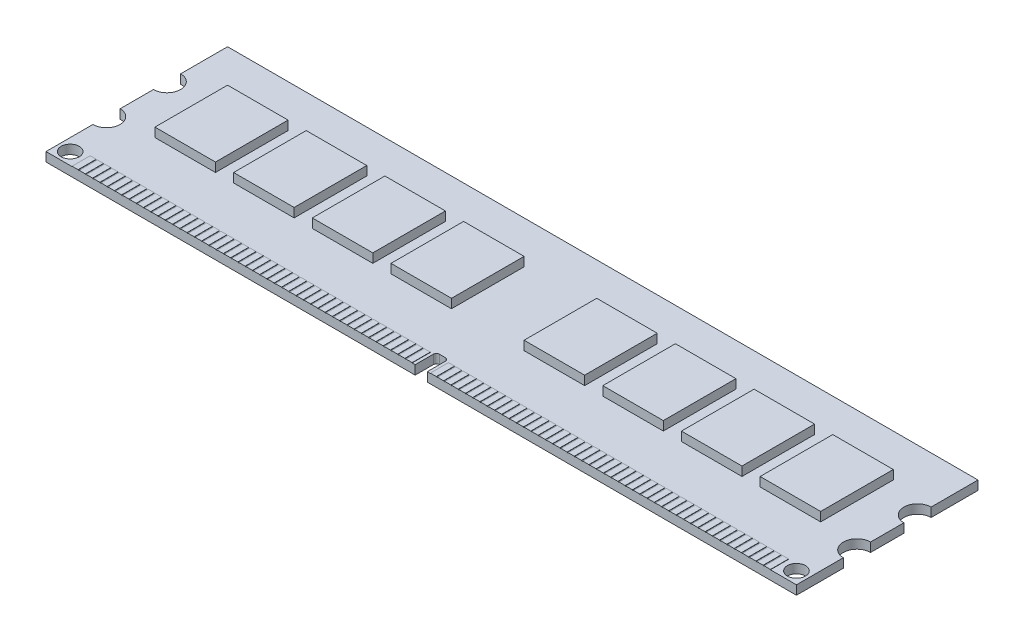
from build123d import *

# Parameters (mm, degrees)
SKETCH1_R                = 1.5
BOSS_EXTRUDE1_DEPTH      = 1.5
SKETCH2_W                = 1
SKETCH2_H                = 3
BOSS_EXTRUDE2_DEPTH      = 0.05
LPATTERN1_COUNT          = 47
LPATTERN1_PITCH          = 1.2
SKETCH3_W                = 10
SKETCH3_H                = 12
BOSS_EXTRUDE3_DEPTH      = 1.5
LPATTERN2_COUNT          = 4
LPATTERN2_PITCH          = 13
MIRROR1_COPY_1_SKETCH_W  = 1
MIRROR1_COPY_1_SKETCH_H  = 3
MIRROR1_COPY_1_DEPTH     = 0.05
MIRROR1_COPY_2_SKETCH_W  = 1
MIRROR1_COPY_2_SKETCH_H  = 3
MIRROR1_COPY_2_DEPTH     = 0.05
MIRROR1_COPY_3_SKETCH_W  = 1
MIRROR1_COPY_3_SKETCH_H  = 3
MIRROR1_COPY_3_DEPTH     = 0.05
MIRROR1_COPY_4_SKETCH_W  = 1
MIRROR1_COPY_4_SKETCH_H  = 3
MIRROR1_COPY_4_DEPTH     = 0.05
MIRROR1_COPY_5_SKETCH_W  = 1
MIRROR1_COPY_5_SKETCH_H  = 3
MIRROR1_COPY_5_DEPTH     = 0.05
MIRROR1_COPY_6_SKETCH_W  = 1
MIRROR1_COPY_6_SKETCH_H  = 3
MIRROR1_COPY_6_DEPTH     = 0.05
MIRROR1_COPY_7_SKETCH_W  = 1
MIRROR1_COPY_7_SKETCH_H  = 3
MIRROR1_COPY_7_DEPTH     = 0.05
MIRROR1_COPY_8_SKETCH_W  = 1
MIRROR1_COPY_8_SKETCH_H  = 3
MIRROR1_COPY_8_DEPTH     = 0.05
MIRROR1_COPY_9_SKETCH_W  = 1
MIRROR1_COPY_9_SKETCH_H  = 3
MIRROR1_COPY_9_DEPTH     = 0.05
MIRROR1_COPY_10_SKETCH_W = 1
MIRROR1_COPY_10_SKETCH_H = 3
MIRROR1_COPY_10_DEPTH    = 0.05
MIRROR1_COPY_11_SKETCH_W = 1
MIRROR1_COPY_11_SKETCH_H = 3
MIRROR1_COPY_11_DEPTH    = 0.05
MIRROR1_COPY_12_SKETCH_W = 1
MIRROR1_COPY_12_SKETCH_H = 3
MIRROR1_COPY_12_DEPTH    = 0.05
MIRROR1_COPY_13_SKETCH_W = 1
MIRROR1_COPY_13_SKETCH_H = 3
MIRROR1_COPY_13_DEPTH    = 0.05
MIRROR1_COPY_14_SKETCH_W = 1
MIRROR1_COPY_14_SKETCH_H = 3
MIRROR1_COPY_14_DEPTH    = 0.05
MIRROR1_COPY_15_SKETCH_W = 1
MIRROR1_COPY_15_SKETCH_H = 3
MIRROR1_COPY_15_DEPTH    = 0.05
MIRROR1_COPY_16_SKETCH_W = 1
MIRROR1_COPY_16_SKETCH_H = 3
MIRROR1_COPY_16_DEPTH    = 0.05
MIRROR1_COPY_17_SKETCH_W = 1
MIRROR1_COPY_17_SKETCH_H = 3
MIRROR1_COPY_17_DEPTH    = 0.05
MIRROR1_COPY_18_SKETCH_W = 1
MIRROR1_COPY_18_SKETCH_H = 3
MIRROR1_COPY_18_DEPTH    = 0.05
MIRROR1_COPY_19_SKETCH_W = 1
MIRROR1_COPY_19_SKETCH_H = 3
MIRROR1_COPY_19_DEPTH    = 0.05
MIRROR1_COPY_20_SKETCH_W = 1
MIRROR1_COPY_20_SKETCH_H = 3
MIRROR1_COPY_20_DEPTH    = 0.05
MIRROR1_COPY_21_SKETCH_W = 1
MIRROR1_COPY_21_SKETCH_H = 3
MIRROR1_COPY_21_DEPTH    = 0.05
MIRROR1_COPY_22_SKETCH_W = 1
MIRROR1_COPY_22_SKETCH_H = 3
MIRROR1_COPY_22_DEPTH    = 0.05
MIRROR1_COPY_23_SKETCH_W = 1
MIRROR1_COPY_23_SKETCH_H = 3
MIRROR1_COPY_23_DEPTH    = 0.05
MIRROR1_COPY_24_SKETCH_W = 1
MIRROR1_COPY_24_SKETCH_H = 3
MIRROR1_COPY_24_DEPTH    = 0.05
MIRROR1_COPY_25_SKETCH_W = 1
MIRROR1_COPY_25_SKETCH_H = 3
MIRROR1_COPY_25_DEPTH    = 0.05
MIRROR1_COPY_26_SKETCH_W = 1
MIRROR1_COPY_26_SKETCH_H = 3
MIRROR1_COPY_26_DEPTH    = 0.05
MIRROR1_COPY_27_SKETCH_W = 1
MIRROR1_COPY_27_SKETCH_H = 3
MIRROR1_COPY_27_DEPTH    = 0.05
MIRROR1_COPY_28_SKETCH_W = 1
MIRROR1_COPY_28_SKETCH_H = 3
MIRROR1_COPY_28_DEPTH    = 0.05
MIRROR1_COPY_29_SKETCH_W = 1
MIRROR1_COPY_29_SKETCH_H = 3
MIRROR1_COPY_29_DEPTH    = 0.05
MIRROR1_COPY_30_SKETCH_W = 1
MIRROR1_COPY_30_SKETCH_H = 3
MIRROR1_COPY_30_DEPTH    = 0.05
MIRROR1_COPY_31_SKETCH_W = 1
MIRROR1_COPY_31_SKETCH_H = 3
MIRROR1_COPY_31_DEPTH    = 0.05
MIRROR1_COPY_32_SKETCH_W = 1
MIRROR1_COPY_32_SKETCH_H = 3
MIRROR1_COPY_32_DEPTH    = 0.05
MIRROR1_COPY_33_SKETCH_W = 1
MIRROR1_COPY_33_SKETCH_H = 3
MIRROR1_COPY_33_DEPTH    = 0.05
MIRROR1_COPY_34_SKETCH_W = 1
MIRROR1_COPY_34_SKETCH_H = 3
MIRROR1_COPY_34_DEPTH    = 0.05
MIRROR1_COPY_35_SKETCH_W = 1
MIRROR1_COPY_35_SKETCH_H = 3
MIRROR1_COPY_35_DEPTH    = 0.05
MIRROR1_COPY_36_SKETCH_W = 1
MIRROR1_COPY_36_SKETCH_H = 3
MIRROR1_COPY_36_DEPTH    = 0.05
MIRROR1_COPY_37_SKETCH_W = 1
MIRROR1_COPY_37_SKETCH_H = 3
MIRROR1_COPY_37_DEPTH    = 0.05
MIRROR1_COPY_38_SKETCH_W = 1
MIRROR1_COPY_38_SKETCH_H = 3
MIRROR1_COPY_38_DEPTH    = 0.05
MIRROR1_COPY_39_SKETCH_W = 1
MIRROR1_COPY_39_SKETCH_H = 3
MIRROR1_COPY_39_DEPTH    = 0.05
MIRROR1_COPY_40_SKETCH_W = 1
MIRROR1_COPY_40_SKETCH_H = 3
MIRROR1_COPY_40_DEPTH    = 0.05
MIRROR1_COPY_41_SKETCH_W = 1
MIRROR1_COPY_41_SKETCH_H = 3
MIRROR1_COPY_41_DEPTH    = 0.05
MIRROR1_COPY_42_SKETCH_W = 1
MIRROR1_COPY_42_SKETCH_H = 3
MIRROR1_COPY_42_DEPTH    = 0.05
MIRROR1_COPY_43_SKETCH_W = 1
MIRROR1_COPY_43_SKETCH_H = 3
MIRROR1_COPY_43_DEPTH    = 0.05
MIRROR1_COPY_44_SKETCH_W = 1
MIRROR1_COPY_44_SKETCH_H = 3
MIRROR1_COPY_44_DEPTH    = 0.05
MIRROR1_COPY_45_SKETCH_W = 1
MIRROR1_COPY_45_SKETCH_H = 3
MIRROR1_COPY_45_DEPTH    = 0.05
MIRROR1_COPY_46_SKETCH_W = 1
MIRROR1_COPY_46_SKETCH_H = 3
MIRROR1_COPY_46_DEPTH    = 0.05
MIRROR1_COPY_47_SKETCH_W = 10
MIRROR1_COPY_47_SKETCH_H = 12
MIRROR1_COPY_47_DEPTH    = 1.5
MIRROR1_COPY_48_SKETCH_W = 10
MIRROR1_COPY_48_SKETCH_H = 12
MIRROR1_COPY_48_DEPTH    = 1.5
MIRROR1_COPY_49_SKETCH_W = 10
MIRROR1_COPY_49_SKETCH_H = 12
MIRROR1_COPY_49_DEPTH    = 1.5


with BuildPart() as part:
    # Sketch1 → Boss-Extrude1 (new body)
    with BuildSketch(Plane(origin=(0, 0, 0), x_dir=(1, 0, 0), z_dir=(0, 1, 0))):
        with BuildLine():
            Line((1, 0), (1, 3))
            ThreePointArc((1, 3), (0.853553391, 3.353553391), (0.5, 3.5))
            Line((0.5, 3.5), (0, 3.5))
            Line((0, 3.5), (0, 30))
            Line((0, 30), (62, 30))
            Line((62, 30), (62, 22.25))
            ThreePointArc((62, 22.25), (59.75, 20), (62, 17.75))
            Line((62, 17.75), (62, 12.25))
            ThreePointArc((62, 12.25), (59.75, 10), (62, 7.75))
            Line((62, 7.75), (62, 0))
            Line((62, 0), (1, 0))
        make_face()
        with Locations((60, 2)):
            Circle(SKETCH1_R, mode=Mode.SUBTRACT)
    boss_extrude1 = extrude(amount=BOSS_EXTRUDE1_DEPTH)

    # Sketch2 → Boss-Extrude2 (add)
    with BuildSketch(Plane(origin=(0, 1.5, 0), x_dir=(1, 0, 0), z_dir=(0, 1, 0))):
        with Locations((2, 1.5)):
            Rectangle(SKETCH2_W, SKETCH2_H)
    boss_extrude2 = extrude(amount=BOSS_EXTRUDE2_DEPTH)

    # LPattern1: Boss-Extrude2 ×47
    with Locations(*[(i * LPATTERN1_PITCH, 0, 0) for i in range(1, LPATTERN1_COUNT)]):
        add(boss_extrude2)

    # Sketch3 → Boss-Extrude3 (add)
    with BuildSketch(Plane(origin=(0, 1.5, 0), x_dir=(1, 0, 0), z_dir=(0, 1, 0))):
        with Locations((50, 17)):
            Rectangle(SKETCH3_W, SKETCH3_H)
    boss_extrude3 = extrude(amount=BOSS_EXTRUDE3_DEPTH)

    # LPattern2: Boss-Extrude3 ×4
    with Locations(*[(-i * LPATTERN2_PITCH, 0, 0) for i in range(1, LPATTERN2_COUNT)]):
        add(boss_extrude3)

    # Mirror1: Boss-Extrude3, Boss-Extrude2, Boss-Extrude1 across plane
    add(boss_extrude3.mirror(Plane(origin=(0, 0, 0), x_dir=(0, 0, 1), z_dir=(1, 0, 0))))
    add(boss_extrude2.mirror(Plane(origin=(0, 0, 0), x_dir=(0, 0, 1), z_dir=(1, 0, 0))))
    add(boss_extrude1.mirror(Plane(origin=(0, 0, 0), x_dir=(0, 0, 1), z_dir=(1, 0, 0))))

    # Mirror1 copy 1 sketch → Mirror1 copy 1 (add)
    with BuildSketch(Plane(origin=(-1.2, 1.5, 0), x_dir=(-1, 0, 0), z_dir=(0, 1, 0))):
        with Locations((2, -1.5)):
            Rectangle(MIRROR1_COPY_1_SKETCH_W, MIRROR1_COPY_1_SKETCH_H)
    extrude(amount=MIRROR1_COPY_1_DEPTH)

    # Mirror1 copy 2 sketch → Mirror1 copy 2 (add)
    with BuildSketch(Plane(origin=(-2.4, 1.5, 0), x_dir=(-1, 0, 0), z_dir=(0, 1, 0))):
        with Locations((2, -1.5)):
            Rectangle(MIRROR1_COPY_2_SKETCH_W, MIRROR1_COPY_2_SKETCH_H)
    extrude(amount=MIRROR1_COPY_2_DEPTH)

    # Mirror1 copy 3 sketch → Mirror1 copy 3 (add)
    with BuildSketch(Plane(origin=(-3.6, 1.5, 0), x_dir=(-1, 0, 0), z_dir=(0, 1, 0))):
        with Locations((2, -1.5)):
            Rectangle(MIRROR1_COPY_3_SKETCH_W, MIRROR1_COPY_3_SKETCH_H)
    extrude(amount=MIRROR1_COPY_3_DEPTH)

    # Mirror1 copy 4 sketch → Mirror1 copy 4 (add)
    with BuildSketch(Plane(origin=(-4.8, 1.5, 0), x_dir=(-1, 0, 0), z_dir=(0, 1, 0))):
        with Locations((2, -1.5)):
            Rectangle(MIRROR1_COPY_4_SKETCH_W, MIRROR1_COPY_4_SKETCH_H)
    extrude(amount=MIRROR1_COPY_4_DEPTH)

    # Mirror1 copy 5 sketch → Mirror1 copy 5 (add)
    with BuildSketch(Plane(origin=(-6, 1.5, 0), x_dir=(-1, 0, 0), z_dir=(0, 1, 0))):
        with Locations((2, -1.5)):
            Rectangle(MIRROR1_COPY_5_SKETCH_W, MIRROR1_COPY_5_SKETCH_H)
    extrude(amount=MIRROR1_COPY_5_DEPTH)

    # Mirror1 copy 6 sketch → Mirror1 copy 6 (add)
    with BuildSketch(Plane(origin=(-7.2, 1.5, 0), x_dir=(-1, 0, 0), z_dir=(0, 1, 0))):
        with Locations((2, -1.5)):
            Rectangle(MIRROR1_COPY_6_SKETCH_W, MIRROR1_COPY_6_SKETCH_H)
    extrude(amount=MIRROR1_COPY_6_DEPTH)

    # Mirror1 copy 7 sketch → Mirror1 copy 7 (add)
    with BuildSketch(Plane(origin=(-8.4, 1.5, 0), x_dir=(-1, 0, 0), z_dir=(0, 1, 0))):
        with Locations((2, -1.5)):
            Rectangle(MIRROR1_COPY_7_SKETCH_W, MIRROR1_COPY_7_SKETCH_H)
    extrude(amount=MIRROR1_COPY_7_DEPTH)

    # Mirror1 copy 8 sketch → Mirror1 copy 8 (add)
    with BuildSketch(Plane(origin=(-9.6, 1.5, 0), x_dir=(-1, 0, 0), z_dir=(0, 1, 0))):
        with Locations((2, -1.5)):
            Rectangle(MIRROR1_COPY_8_SKETCH_W, MIRROR1_COPY_8_SKETCH_H)
    extrude(amount=MIRROR1_COPY_8_DEPTH)

    # Mirror1 copy 9 sketch → Mirror1 copy 9 (add)
    with BuildSketch(Plane(origin=(-10.8, 1.5, 0), x_dir=(-1, 0, 0), z_dir=(0, 1, 0))):
        with Locations((2, -1.5)):
            Rectangle(MIRROR1_COPY_9_SKETCH_W, MIRROR1_COPY_9_SKETCH_H)
    extrude(amount=MIRROR1_COPY_9_DEPTH)

    # Mirror1 copy 10 sketch → Mirror1 copy 10 (add)
    with BuildSketch(Plane(origin=(-12, 1.5, 0), x_dir=(-1, 0, 0), z_dir=(0, 1, 0))):
        with Locations((2, -1.5)):
            Rectangle(MIRROR1_COPY_10_SKETCH_W, MIRROR1_COPY_10_SKETCH_H)
    extrude(amount=MIRROR1_COPY_10_DEPTH)

    # Mirror1 copy 11 sketch → Mirror1 copy 11 (add)
    with BuildSketch(Plane(origin=(-13.2, 1.5, 0), x_dir=(-1, 0, 0), z_dir=(0, 1, 0))):
        with Locations((2, -1.5)):
            Rectangle(MIRROR1_COPY_11_SKETCH_W, MIRROR1_COPY_11_SKETCH_H)
    extrude(amount=MIRROR1_COPY_11_DEPTH)

    # Mirror1 copy 12 sketch → Mirror1 copy 12 (add)
    with BuildSketch(Plane(origin=(-14.4, 1.5, 0), x_dir=(-1, 0, 0), z_dir=(0, 1, 0))):
        with Locations((2, -1.5)):
            Rectangle(MIRROR1_COPY_12_SKETCH_W, MIRROR1_COPY_12_SKETCH_H)
    extrude(amount=MIRROR1_COPY_12_DEPTH)

    # Mirror1 copy 13 sketch → Mirror1 copy 13 (add)
    with BuildSketch(Plane(origin=(-15.6, 1.5, 0), x_dir=(-1, 0, 0), z_dir=(0, 1, 0))):
        with Locations((2, -1.5)):
            Rectangle(MIRROR1_COPY_13_SKETCH_W, MIRROR1_COPY_13_SKETCH_H)
    extrude(amount=MIRROR1_COPY_13_DEPTH)

    # Mirror1 copy 14 sketch → Mirror1 copy 14 (add)
    with BuildSketch(Plane(origin=(-16.8, 1.5, 0), x_dir=(-1, 0, 0), z_dir=(0, 1, 0))):
        with Locations((2, -1.5)):
            Rectangle(MIRROR1_COPY_14_SKETCH_W, MIRROR1_COPY_14_SKETCH_H)
    extrude(amount=MIRROR1_COPY_14_DEPTH)

    # Mirror1 copy 15 sketch → Mirror1 copy 15 (add)
    with BuildSketch(Plane(origin=(-18, 1.5, 0), x_dir=(-1, 0, 0), z_dir=(0, 1, 0))):
        with Locations((2, -1.5)):
            Rectangle(MIRROR1_COPY_15_SKETCH_W, MIRROR1_COPY_15_SKETCH_H)
    extrude(amount=MIRROR1_COPY_15_DEPTH)

    # Mirror1 copy 16 sketch → Mirror1 copy 16 (add)
    with BuildSketch(Plane(origin=(-19.2, 1.5, 0), x_dir=(-1, 0, 0), z_dir=(0, 1, 0))):
        with Locations((2, -1.5)):
            Rectangle(MIRROR1_COPY_16_SKETCH_W, MIRROR1_COPY_16_SKETCH_H)
    extrude(amount=MIRROR1_COPY_16_DEPTH)

    # Mirror1 copy 17 sketch → Mirror1 copy 17 (add)
    with BuildSketch(Plane(origin=(-20.4, 1.5, 0), x_dir=(-1, 0, 0), z_dir=(0, 1, 0))):
        with Locations((2, -1.5)):
            Rectangle(MIRROR1_COPY_17_SKETCH_W, MIRROR1_COPY_17_SKETCH_H)
    extrude(amount=MIRROR1_COPY_17_DEPTH)

    # Mirror1 copy 18 sketch → Mirror1 copy 18 (add)
    with BuildSketch(Plane(origin=(-21.6, 1.5, 0), x_dir=(-1, 0, 0), z_dir=(0, 1, 0))):
        with Locations((2, -1.5)):
            Rectangle(MIRROR1_COPY_18_SKETCH_W, MIRROR1_COPY_18_SKETCH_H)
    extrude(amount=MIRROR1_COPY_18_DEPTH)

    # Mirror1 copy 19 sketch → Mirror1 copy 19 (add)
    with BuildSketch(Plane(origin=(-22.8, 1.5, 0), x_dir=(-1, 0, 0), z_dir=(0, 1, 0))):
        with Locations((2, -1.5)):
            Rectangle(MIRROR1_COPY_19_SKETCH_W, MIRROR1_COPY_19_SKETCH_H)
    extrude(amount=MIRROR1_COPY_19_DEPTH)

    # Mirror1 copy 20 sketch → Mirror1 copy 20 (add)
    with BuildSketch(Plane(origin=(-24, 1.5, 0), x_dir=(-1, 0, 0), z_dir=(0, 1, 0))):
        with Locations((2, -1.5)):
            Rectangle(MIRROR1_COPY_20_SKETCH_W, MIRROR1_COPY_20_SKETCH_H)
    extrude(amount=MIRROR1_COPY_20_DEPTH)

    # Mirror1 copy 21 sketch → Mirror1 copy 21 (add)
    with BuildSketch(Plane(origin=(-25.2, 1.5, 0), x_dir=(-1, 0, 0), z_dir=(0, 1, 0))):
        with Locations((2, -1.5)):
            Rectangle(MIRROR1_COPY_21_SKETCH_W, MIRROR1_COPY_21_SKETCH_H)
    extrude(amount=MIRROR1_COPY_21_DEPTH)

    # Mirror1 copy 22 sketch → Mirror1 copy 22 (add)
    with BuildSketch(Plane(origin=(-26.4, 1.5, 0), x_dir=(-1, 0, 0), z_dir=(0, 1, 0))):
        with Locations((2, -1.5)):
            Rectangle(MIRROR1_COPY_22_SKETCH_W, MIRROR1_COPY_22_SKETCH_H)
    extrude(amount=MIRROR1_COPY_22_DEPTH)

    # Mirror1 copy 23 sketch → Mirror1 copy 23 (add)
    with BuildSketch(Plane(origin=(-27.6, 1.5, 0), x_dir=(-1, 0, 0), z_dir=(0, 1, 0))):
        with Locations((2, -1.5)):
            Rectangle(MIRROR1_COPY_23_SKETCH_W, MIRROR1_COPY_23_SKETCH_H)
    extrude(amount=MIRROR1_COPY_23_DEPTH)

    # Mirror1 copy 24 sketch → Mirror1 copy 24 (add)
    with BuildSketch(Plane(origin=(-28.8, 1.5, 0), x_dir=(-1, 0, 0), z_dir=(0, 1, 0))):
        with Locations((2, -1.5)):
            Rectangle(MIRROR1_COPY_24_SKETCH_W, MIRROR1_COPY_24_SKETCH_H)
    extrude(amount=MIRROR1_COPY_24_DEPTH)

    # Mirror1 copy 25 sketch → Mirror1 copy 25 (add)
    with BuildSketch(Plane(origin=(-30, 1.5, 0), x_dir=(-1, 0, 0), z_dir=(0, 1, 0))):
        with Locations((2, -1.5)):
            Rectangle(MIRROR1_COPY_25_SKETCH_W, MIRROR1_COPY_25_SKETCH_H)
    extrude(amount=MIRROR1_COPY_25_DEPTH)

    # Mirror1 copy 26 sketch → Mirror1 copy 26 (add)
    with BuildSketch(Plane(origin=(-31.2, 1.5, 0), x_dir=(-1, 0, 0), z_dir=(0, 1, 0))):
        with Locations((2, -1.5)):
            Rectangle(MIRROR1_COPY_26_SKETCH_W, MIRROR1_COPY_26_SKETCH_H)
    extrude(amount=MIRROR1_COPY_26_DEPTH)

    # Mirror1 copy 27 sketch → Mirror1 copy 27 (add)
    with BuildSketch(Plane(origin=(-32.4, 1.5, 0), x_dir=(-1, 0, 0), z_dir=(0, 1, 0))):
        with Locations((2, -1.5)):
            Rectangle(MIRROR1_COPY_27_SKETCH_W, MIRROR1_COPY_27_SKETCH_H)
    extrude(amount=MIRROR1_COPY_27_DEPTH)

    # Mirror1 copy 28 sketch → Mirror1 copy 28 (add)
    with BuildSketch(Plane(origin=(-33.6, 1.5, 0), x_dir=(-1, 0, 0), z_dir=(0, 1, 0))):
        with Locations((2, -1.5)):
            Rectangle(MIRROR1_COPY_28_SKETCH_W, MIRROR1_COPY_28_SKETCH_H)
    extrude(amount=MIRROR1_COPY_28_DEPTH)

    # Mirror1 copy 29 sketch → Mirror1 copy 29 (add)
    with BuildSketch(Plane(origin=(-34.8, 1.5, 0), x_dir=(-1, 0, 0), z_dir=(0, 1, 0))):
        with Locations((2, -1.5)):
            Rectangle(MIRROR1_COPY_29_SKETCH_W, MIRROR1_COPY_29_SKETCH_H)
    extrude(amount=MIRROR1_COPY_29_DEPTH)

    # Mirror1 copy 30 sketch → Mirror1 copy 30 (add)
    with BuildSketch(Plane(origin=(-36, 1.5, 0), x_dir=(-1, 0, 0), z_dir=(0, 1, 0))):
        with Locations((2, -1.5)):
            Rectangle(MIRROR1_COPY_30_SKETCH_W, MIRROR1_COPY_30_SKETCH_H)
    extrude(amount=MIRROR1_COPY_30_DEPTH)

    # Mirror1 copy 31 sketch → Mirror1 copy 31 (add)
    with BuildSketch(Plane(origin=(-37.2, 1.5, 0), x_dir=(-1, 0, 0), z_dir=(0, 1, 0))):
        with Locations((2, -1.5)):
            Rectangle(MIRROR1_COPY_31_SKETCH_W, MIRROR1_COPY_31_SKETCH_H)
    extrude(amount=MIRROR1_COPY_31_DEPTH)

    # Mirror1 copy 32 sketch → Mirror1 copy 32 (add)
    with BuildSketch(Plane(origin=(-38.4, 1.5, 0), x_dir=(-1, 0, 0), z_dir=(0, 1, 0))):
        with Locations((2, -1.5)):
            Rectangle(MIRROR1_COPY_32_SKETCH_W, MIRROR1_COPY_32_SKETCH_H)
    extrude(amount=MIRROR1_COPY_32_DEPTH)

    # Mirror1 copy 33 sketch → Mirror1 copy 33 (add)
    with BuildSketch(Plane(origin=(-39.6, 1.5, 0), x_dir=(-1, 0, 0), z_dir=(0, 1, 0))):
        with Locations((2, -1.5)):
            Rectangle(MIRROR1_COPY_33_SKETCH_W, MIRROR1_COPY_33_SKETCH_H)
    extrude(amount=MIRROR1_COPY_33_DEPTH)

    # Mirror1 copy 34 sketch → Mirror1 copy 34 (add)
    with BuildSketch(Plane(origin=(-40.8, 1.5, 0), x_dir=(-1, 0, 0), z_dir=(0, 1, 0))):
        with Locations((2, -1.5)):
            Rectangle(MIRROR1_COPY_34_SKETCH_W, MIRROR1_COPY_34_SKETCH_H)
    extrude(amount=MIRROR1_COPY_34_DEPTH)

    # Mirror1 copy 35 sketch → Mirror1 copy 35 (add)
    with BuildSketch(Plane(origin=(-42, 1.5, 0), x_dir=(-1, 0, 0), z_dir=(0, 1, 0))):
        with Locations((2, -1.5)):
            Rectangle(MIRROR1_COPY_35_SKETCH_W, MIRROR1_COPY_35_SKETCH_H)
    extrude(amount=MIRROR1_COPY_35_DEPTH)

    # Mirror1 copy 36 sketch → Mirror1 copy 36 (add)
    with BuildSketch(Plane(origin=(-43.2, 1.5, 0), x_dir=(-1, 0, 0), z_dir=(0, 1, 0))):
        with Locations((2, -1.5)):
            Rectangle(MIRROR1_COPY_36_SKETCH_W, MIRROR1_COPY_36_SKETCH_H)
    extrude(amount=MIRROR1_COPY_36_DEPTH)

    # Mirror1 copy 37 sketch → Mirror1 copy 37 (add)
    with BuildSketch(Plane(origin=(-44.4, 1.5, 0), x_dir=(-1, 0, 0), z_dir=(0, 1, 0))):
        with Locations((2, -1.5)):
            Rectangle(MIRROR1_COPY_37_SKETCH_W, MIRROR1_COPY_37_SKETCH_H)
    extrude(amount=MIRROR1_COPY_37_DEPTH)

    # Mirror1 copy 38 sketch → Mirror1 copy 38 (add)
    with BuildSketch(Plane(origin=(-45.6, 1.5, 0), x_dir=(-1, 0, 0), z_dir=(0, 1, 0))):
        with Locations((2, -1.5)):
            Rectangle(MIRROR1_COPY_38_SKETCH_W, MIRROR1_COPY_38_SKETCH_H)
    extrude(amount=MIRROR1_COPY_38_DEPTH)

    # Mirror1 copy 39 sketch → Mirror1 copy 39 (add)
    with BuildSketch(Plane(origin=(-46.8, 1.5, 0), x_dir=(-1, 0, 0), z_dir=(0, 1, 0))):
        with Locations((2, -1.5)):
            Rectangle(MIRROR1_COPY_39_SKETCH_W, MIRROR1_COPY_39_SKETCH_H)
    extrude(amount=MIRROR1_COPY_39_DEPTH)

    # Mirror1 copy 40 sketch → Mirror1 copy 40 (add)
    with BuildSketch(Plane(origin=(-48, 1.5, 0), x_dir=(-1, 0, 0), z_dir=(0, 1, 0))):
        with Locations((2, -1.5)):
            Rectangle(MIRROR1_COPY_40_SKETCH_W, MIRROR1_COPY_40_SKETCH_H)
    extrude(amount=MIRROR1_COPY_40_DEPTH)

    # Mirror1 copy 41 sketch → Mirror1 copy 41 (add)
    with BuildSketch(Plane(origin=(-49.2, 1.5, 0), x_dir=(-1, 0, 0), z_dir=(0, 1, 0))):
        with Locations((2, -1.5)):
            Rectangle(MIRROR1_COPY_41_SKETCH_W, MIRROR1_COPY_41_SKETCH_H)
    extrude(amount=MIRROR1_COPY_41_DEPTH)

    # Mirror1 copy 42 sketch → Mirror1 copy 42 (add)
    with BuildSketch(Plane(origin=(-50.4, 1.5, 0), x_dir=(-1, 0, 0), z_dir=(0, 1, 0))):
        with Locations((2, -1.5)):
            Rectangle(MIRROR1_COPY_42_SKETCH_W, MIRROR1_COPY_42_SKETCH_H)
    extrude(amount=MIRROR1_COPY_42_DEPTH)

    # Mirror1 copy 43 sketch → Mirror1 copy 43 (add)
    with BuildSketch(Plane(origin=(-51.6, 1.5, 0), x_dir=(-1, 0, 0), z_dir=(0, 1, 0))):
        with Locations((2, -1.5)):
            Rectangle(MIRROR1_COPY_43_SKETCH_W, MIRROR1_COPY_43_SKETCH_H)
    extrude(amount=MIRROR1_COPY_43_DEPTH)

    # Mirror1 copy 44 sketch → Mirror1 copy 44 (add)
    with BuildSketch(Plane(origin=(-52.8, 1.5, 0), x_dir=(-1, 0, 0), z_dir=(0, 1, 0))):
        with Locations((2, -1.5)):
            Rectangle(MIRROR1_COPY_44_SKETCH_W, MIRROR1_COPY_44_SKETCH_H)
    extrude(amount=MIRROR1_COPY_44_DEPTH)

    # Mirror1 copy 45 sketch → Mirror1 copy 45 (add)
    with BuildSketch(Plane(origin=(-54, 1.5, 0), x_dir=(-1, 0, 0), z_dir=(0, 1, 0))):
        with Locations((2, -1.5)):
            Rectangle(MIRROR1_COPY_45_SKETCH_W, MIRROR1_COPY_45_SKETCH_H)
    extrude(amount=MIRROR1_COPY_45_DEPTH)

    # Mirror1 copy 46 sketch → Mirror1 copy 46 (add)
    with BuildSketch(Plane(origin=(-55.2, 1.5, 0), x_dir=(-1, 0, 0), z_dir=(0, 1, 0))):
        with Locations((2, -1.5)):
            Rectangle(MIRROR1_COPY_46_SKETCH_W, MIRROR1_COPY_46_SKETCH_H)
    extrude(amount=MIRROR1_COPY_46_DEPTH)

    # Mirror1 copy 47 sketch → Mirror1 copy 47 (add)
    with BuildSketch(Plane(origin=(13, 1.5, 0), x_dir=(-1, 0, 0), z_dir=(0, 1, 0))):
        with Locations((50, -17)):
            Rectangle(MIRROR1_COPY_47_SKETCH_W, MIRROR1_COPY_47_SKETCH_H)
    extrude(amount=MIRROR1_COPY_47_DEPTH)

    # Mirror1 copy 48 sketch → Mirror1 copy 48 (add)
    with BuildSketch(Plane(origin=(26, 1.5, 0), x_dir=(-1, 0, 0), z_dir=(0, 1, 0))):
        with Locations((50, -17)):
            Rectangle(MIRROR1_COPY_48_SKETCH_W, MIRROR1_COPY_48_SKETCH_H)
    extrude(amount=MIRROR1_COPY_48_DEPTH)

    # Mirror1 copy 49 sketch → Mirror1 copy 49 (add)
    with BuildSketch(Plane(origin=(39, 1.5, 0), x_dir=(-1, 0, 0), z_dir=(0, 1, 0))):
        with Locations((50, -17)):
            Rectangle(MIRROR1_COPY_49_SKETCH_W, MIRROR1_COPY_49_SKETCH_H)
    extrude(amount=MIRROR1_COPY_49_DEPTH)


solid = part.part
